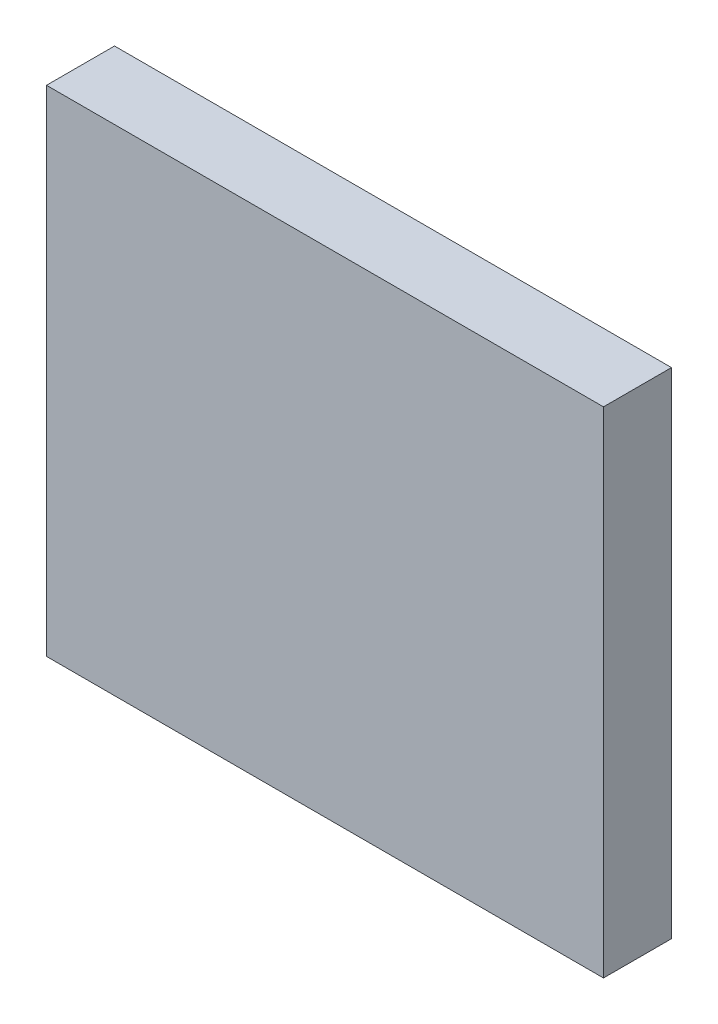
from build123d import *

# Parameters (mm, degrees)
SKETCH1_W           = 81.899741086
SKETCH1_H           = 72.734066091
BOSS_EXTRUDE1_DEPTH = 10


with BuildPart() as part:
    # Sketch1 → Boss-Extrude1 (new body)
    with BuildSketch(Plane.XY):
        with Locations((5.765505239, -7.243839916)):
            Rectangle(SKETCH1_W, SKETCH1_H)
    extrude(amount=BOSS_EXTRUDE1_DEPTH)


solid = part.part
